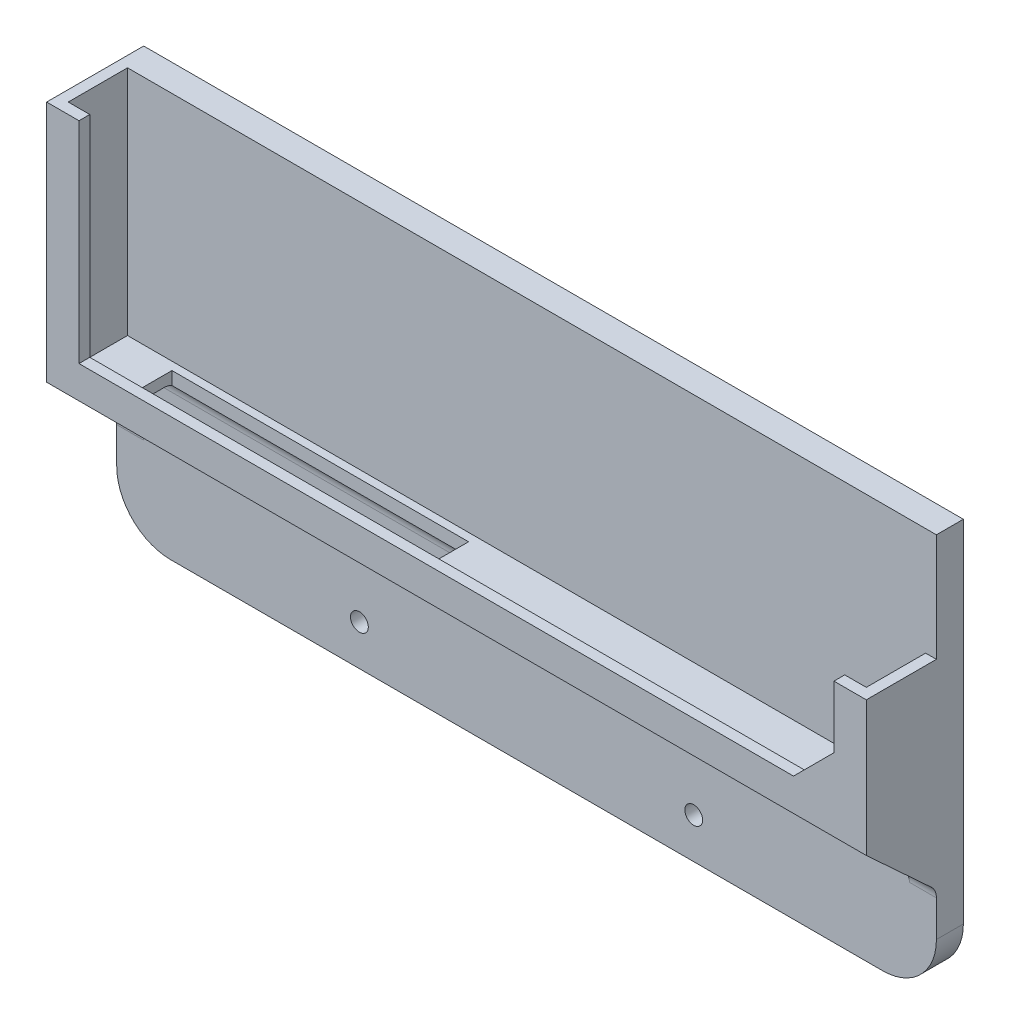
from build123d import *

# Parameters (mm, degrees)
SKETCH1_W           = 152
SKETCH1_H           = 75
SKETCH1_R           = 1.65
BOSS_EXTRUDE1_DEPTH = 5
FILLET1_R           = 10
BOSS_EXTRUDE2_DEPTH = 11
BOSS_EXTRUDE3_DEPTH = 2
CHAMFER1_SIZE       = 7.5
BOSS_EXTRUDE4_DEPTH = 5
FILLET2_R           = 3
SKETCH5_W           = 55
SKETCH5_H           = 8
CUT_EXTRUDE1_DEPTH  = 10


with BuildPart() as part:
    # Sketch1 → Boss-Extrude1 (new body)
    with BuildSketch(Plane.XY):
        with Locations((76, 37.5)):
            Rectangle(SKETCH1_W, SKETCH1_H)
        with Locations((45, 7.5)):
            Circle(SKETCH1_R, mode=Mode.SUBTRACT)
        with Locations((107, 7.5)):
            Circle(SKETCH1_R, mode=Mode.SUBTRACT)
    extrude(amount=BOSS_EXTRUDE1_DEPTH)

    # Fillet1
    fillet1_edges = [part.edges().sort_by_distance(p)[0] for p in [
        (152, 0, 2.5),
        (0, 0, 2.5),
    ]]
    fillet(fillet1_edges, radius=FILLET1_R)

    # Sketch2 → Boss-Extrude2 (add)
    with BuildSketch(Plane.XY.offset(5)):
        Polygon((0, 75), (2, 75), (2, 73), (2, 32), (150, 32), (150, 55), (152, 55), (152, 30), (0, 30), align=None)
    extrude(amount=BOSS_EXTRUDE2_DEPTH)

    # Sketch3 → Boss-Extrude3 (add)
    with BuildSketch(Plane.XY.offset(16)):
        Polygon((152, 30), (152, 55), (146, 55), (146, 36), (6, 36), (6, 75), (0, 75), (0, 30), align=None)
    extrude(amount=BOSS_EXTRUDE3_DEPTH)

    # Chamfer1
    chamfer1_edges = [part.edges().sort_by_distance(p)[0] for p in [
        (146, 36, 17),
    ]]
    chamfer(chamfer1_edges, length=CHAMFER1_SIZE)

    # Sketch4 → Boss-Extrude4 (add)
    with BuildSketch(Plane.ZY):
        Polygon((18, 30), (5, 18), (5, 30), align=None)
    boss_extrude4 = extrude(amount=-BOSS_EXTRUDE4_DEPTH)

    # Mirror1: Boss-Extrude4 across plane
    add(boss_extrude4.mirror(Plane.ZY.offset(-76)))

    # Fillet2
    fillet2_edges = [part.edges().sort_by_distance(p)[0] for p in [
        (149.5, 18, 5),
        (76, 30, 5),
        (2.5, 18, 5),
    ]]
    fillet(fillet2_edges, radius=FILLET2_R)

    # Sketch5 → Cut-Extrude1 (cut)
    with BuildSketch(Plane(origin=(0, 32, 0), x_dir=(1, 0, 0), z_dir=(0, 1, 0))):
        with Locations((39.241088115, -10.5)):
            Rectangle(SKETCH5_W, SKETCH5_H)
    extrude(amount=-CUT_EXTRUDE1_DEPTH, mode=Mode.SUBTRACT)


solid = part.part
